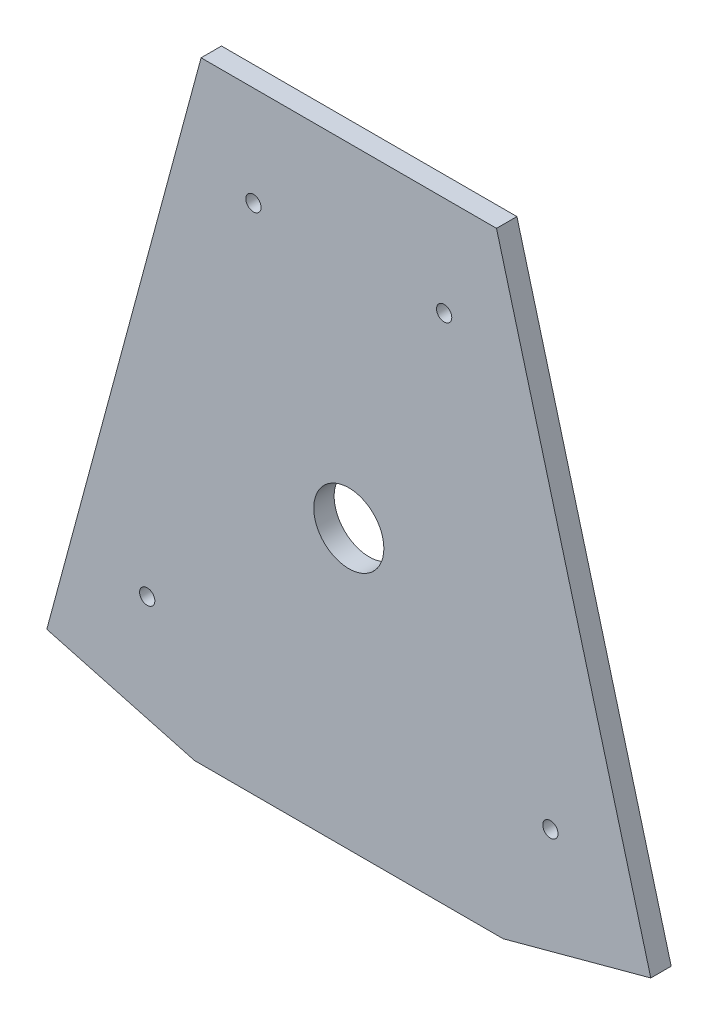
from build123d import *

# Parameters (mm, degrees)
BOSS_EXTRUDE1_DEPTH   = 5.08
SKETCH2_R             = 19.05
SKETCH2_R_2           = 5.55625
CUT_EXTRUDE1_DEPTH    = 6.08
F_6_CLEARANCE_HOLE1_D = 3.7973
SKETCH5_R             = 19.05
SKETCH5_R_2           = 8.73125
SKETCH5_R_3           = 5.55625
BOSS_EXTRUDE2_DEPTH   = 5.08


with BuildPart() as part:
    # Sketch1 → Boss-Extrude1 (new body)
    with BuildSketch(Plane.XY):
        Polygon((-36.785608025, 9.921141176), (36.785608025, 9.921141176), (75.212399069, -132.557717648), (38.426791044, -142.478858824), (-38.426791044, -142.478858824), (-75.212399069, -132.557717648), align=None)
    extrude(amount=BOSS_EXTRUDE1_DEPTH)

    # Sketch2 → Cut-Extrude1 (cut, through all)
    with BuildSketch(Plane.XY.offset(5.08)):
        with Locations((0, -73.157410737)):
            Circle(SKETCH2_R)
        with Locations((-36.5125, -73.157410737)):
            Circle(SKETCH2_R_2)
        with Locations((36.5125, -73.157410737)):
            Circle(SKETCH2_R_2)
    extrude(amount=-CUT_EXTRUDE1_DEPTH, mode=Mode.SUBTRACT)

    # #6 Clearance Hole1 (through all)
    with Locations(Plane.XY.offset(5.08)):
        with Locations((50.205500939, -112.994549553), (-50.205500939, -112.994549553), (-23.749124469, -14.899594819), (23.749124469, -14.899594819)):
            Hole(F_6_CLEARANCE_HOLE1_D / 2)

    # Sketch5 → Boss-Extrude2 (add)
    with BuildSketch(Plane.XY.offset(5.08)):
        with Locations((0, -73.157410737)):
            Circle(SKETCH5_R)
        with Locations((0, -73.157410737)):
            Circle(SKETCH5_R_2, mode=Mode.SUBTRACT)
        with Locations((36.5125, -73.157410737)):
            Circle(SKETCH5_R_3)
        with Locations((-36.5125, -73.157410737)):
            Circle(SKETCH5_R_3)
    extrude(amount=-BOSS_EXTRUDE2_DEPTH)


solid = part.part
